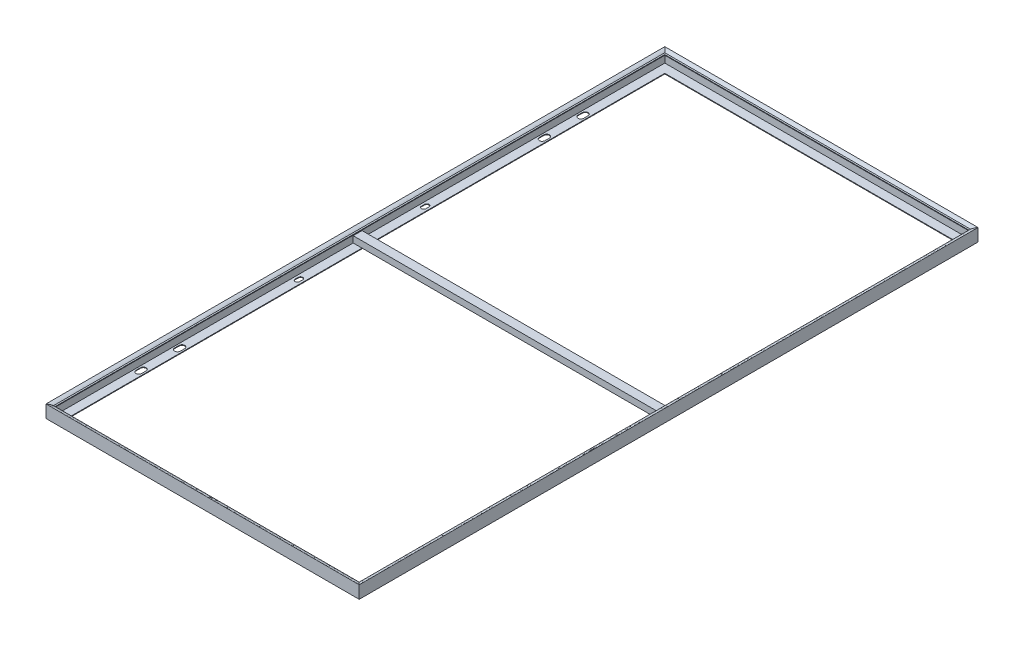
from build123d import *

# Parameters (mm, degrees)
SKETCH2_W           = 3
SKETCH2_H           = 26.5
SKETCH3_W           = 28
SKETCH3_H           = 20
SKETCH3_W_2         = 24
SKETCH3_H_2         = 16
BOSS_EXTRUDE1_DEPTH = 978
CUT_EXTRUDE1_DEPTH  = 2


with BuildPart() as part:
    # Sweep1: sweep along a path in Sketch1
    with BuildLine(Plane(origin=(0, 0, 0), x_dir=(1, 0, 0), z_dir=(0, 1, 0))) as sweep1_path:
        Line((-496, 980), (496, 980))
        Line((496, 980), (496, -980))
        Line((496, -980), (-496, -980))
        Line((-496, -980), (-496, 980))
    # Sketch2 → Sweep1 (sweep)
    with BuildSketch(Plane.XY):
        with BuildLine():
            Line((461, -18), (461, -20))
            Line((461, -20), (496, -20))
            Line((496, -20), (496, 20))
            add(Edge.make_bspline(
                [(485, 15), (480.482366026, 15), (496.005449694, 21.426661948), (496, 20)],
                knots=[0, 0, 0, 0, 1, 1, 1, 1], degree=3))
            Line((485, 15), (494, 15))
            Line((494, 15), (494, 10.5))
            Line((494, 10.5), (484, 10.5))
            Line((484, 10.5), (484, 8.5))
            Line((484, 8.5), (489, 8.5))
            Line((489, 8.5), (489, -18))
            Line((489, -18), (461, -18))
        make_face()
        with Locations((492.5, -4.75)):
            Rectangle(SKETCH2_W, SKETCH2_H, mode=Mode.SUBTRACT)
    sweep(path=sweep1_path.line, transition=Transition.RIGHT)

    # Sketch3 → Boss-Extrude1 (add)
    with BuildSketch(Plane(origin=(-489, 0, 0), x_dir=(0, 0, -1), z_dir=(1, 0, 0))):
        with Locations((0, -8)):
            Rectangle(SKETCH3_W, SKETCH3_H)
        with Locations((0, -8)):
            Rectangle(SKETCH3_W_2, SKETCH3_H_2, mode=Mode.SUBTRACT)
    extrude(amount=BOSS_EXTRUDE1_DEPTH)

    # Sketch4 → Cut-Extrude1 (cut)
    with BuildSketch(Plane.XZ.offset(20)):
        with BuildLine():
            Line((482, 205), (482, 195))
            ThreePointArc((482, 195), (475, 188), (468, 195))
            Line((468, 195), (468, 205))
            ThreePointArc((468, 205), (475, 212), (482, 205))
        make_face()
        with BuildLine():
            Line((484, 584.5), (484, 570.5))
            ThreePointArc((484, 570.5), (475, 561.5), (466, 570.5))
            Line((466, 570.5), (466, 584.5))
            ThreePointArc((466, 584.5), (475, 593.5), (484, 584.5))
        make_face()
        with BuildLine():
            Line((484, 707), (484, 693))
            ThreePointArc((484, 693), (475, 684), (466, 693))
            Line((466, 693), (466, 707))
            ThreePointArc((466, 707), (475, 716), (484, 707))
        make_face()
        with BuildLine():
            Line((-484, 707), (-484, 693))
            ThreePointArc((-484, 693), (-475, 684), (-466, 693))
            Line((-466, 693), (-466, 707))
            ThreePointArc((-466, 707), (-475, 716), (-484, 707))
        make_face()
        with BuildLine():
            Line((-484, 584.5), (-484, 570.5))
            ThreePointArc((-484, 570.5), (-475, 561.5), (-466, 570.5))
            Line((-466, 570.5), (-466, 584.5))
            ThreePointArc((-466, 584.5), (-475, 593.5), (-484, 584.5))
        make_face()
        with BuildLine():
            Line((-482, 205), (-482, 195))
            ThreePointArc((-482, 195), (-475, 188), (-468, 195))
            Line((-468, 195), (-468, 205))
            ThreePointArc((-468, 205), (-475, 212), (-482, 205))
        make_face()
        with BuildLine():
            Line((-482, -205), (-482, -195))
            ThreePointArc((-482, -195), (-475, -188), (-468, -195))
            Line((-468, -195), (-468, -205))
            ThreePointArc((-468, -205), (-475, -212), (-482, -205))
        make_face()
        with BuildLine():
            Line((-484, -584.5), (-484, -570.5))
            ThreePointArc((-484, -570.5), (-475, -561.5), (-466, -570.5))
            Line((-466, -570.5), (-466, -584.5))
            ThreePointArc((-466, -584.5), (-475, -593.5), (-484, -584.5))
        make_face()
        with BuildLine():
            Line((-484, -707), (-484, -693))
            ThreePointArc((-484, -693), (-475, -684), (-466, -693))
            Line((-466, -693), (-466, -707))
            ThreePointArc((-466, -707), (-475, -716), (-484, -707))
        make_face()
        with BuildLine():
            Line((484, -707), (484, -693))
            ThreePointArc((484, -693), (475, -684), (466, -693))
            Line((466, -693), (466, -707))
            ThreePointArc((466, -707), (475, -716), (484, -707))
        make_face()
        with BuildLine():
            Line((484, -584.5), (484, -570.5))
            ThreePointArc((484, -570.5), (475, -561.5), (466, -570.5))
            Line((466, -570.5), (466, -584.5))
            ThreePointArc((466, -584.5), (475, -593.5), (484, -584.5))
        make_face()
        with BuildLine():
            Line((482, -205), (482, -195))
            ThreePointArc((482, -195), (475, -188), (468, -195))
            Line((468, -195), (468, -205))
            ThreePointArc((468, -205), (475, -212), (482, -205))
        make_face()
    extrude(amount=-CUT_EXTRUDE1_DEPTH, mode=Mode.SUBTRACT)


solid = part.part
